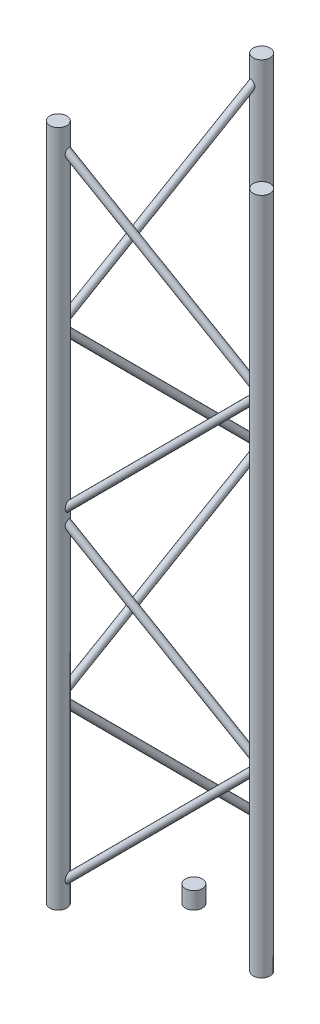
from build123d import *

# Parameters (mm, degrees)
SKETCH2_R                      = 25
BOSS_EXTRUDE2_DEPTH            = 50
SKETCH1_R                      = 25
BOSS_EXTRUDE1_DEPTH            = 2000
CIRPATTERN1_COUNT              = 3
SKETCH16_ON_SEGMENT_1_R        = 10.65
SKETCH16_ON_SEGMENT_1_R_2      = 8.35
PIPE_21_3_X_2_3_3_DEPTH        = 698.900964125
SKETCH16_ON_SEGMENT_2_R        = 10.65
SKETCH16_ON_SEGMENT_2_R_2      = 8.35
PIPE_21_3_X_2_3_3_2_DEPTH      = 715.434725051
SKETCH16_ON_SEGMENT_3_R        = 10.65
SKETCH16_ON_SEGMENT_3_R_2      = 8.35
PIPE_21_3_X_2_3_3_3_DEPTH      = 715.434725051
SKETCH16_R                     = 10.65
SKETCH16_R_2                   = 8.35
PIPE_21_3_X_2_3_3_4_DEPTH      = 682.367203198
PIPE_21_3_X_2_3_3_4_DEPTH_BACK = 16.533760927
CIRPATTERN2_COUNT              = 3


with BuildPart() as part:
    # Sketch2 → Boss-Extrude2 (new body)
    with BuildSketch(Plane(origin=(0, 0, 0), x_dir=(1, 0, 0), z_dir=(0, 1, 0))):
        with Locations(Location((0, 0, 0), (0, 0, 270))):  # turned: the seam where the file's is
            Circle(SKETCH2_R)
    extrude(amount=BOSS_EXTRUDE2_DEPTH)


with BuildPart() as body_2:
    # Sketch1 → Boss-Extrude1 (new body)
    with BuildSketch(Plane(origin=(0, 0, 0), x_dir=(1, 0, 0), z_dir=(0, 1, 0))):
        with Locations(Location((-200, -200, 0), (0, 0, 270))):  # turned: the seam where the file's is
            Circle(SKETCH1_R)
    extrude(amount=BOSS_EXTRUDE1_DEPTH)


with BuildPart() as cirpattern1_1:
    # CirPattern1: pattern copy
    add(body_2.part.rotate(Axis((0, 0, 0), (0, 1, 0)), 1 * 360 / CIRPATTERN1_COUNT))


with BuildPart() as cirpattern1_2:
    # CirPattern1: pattern copy
    add(body_2.part.rotate(Axis((0, 0, 0), (0, 1, 0)), 2 * 360 / CIRPATTERN1_COUNT))


with BuildPart() as body_5:
    # Sketch16 on segment 1 (carried to segment 1) → Pipe 21.3 X 2.3(3) (new body)
    with BuildSketch(Plane(origin=(273.205080757, 50, 73.205080757), x_dir=(-0.492221372, -0.717938884, -0.492221372), z_dir=(-0.507659454, 0.69610614, -0.507659454))):
        Circle(SKETCH16_ON_SEGMENT_1_R)
        Circle(SKETCH16_ON_SEGMENT_1_R_2, mode=Mode.SUBTRACT)
    extrude(amount=PIPE_21_3_X_2_3_3_DEPTH)

    # Pipe 21.3 X 2.3(3) mitre 1
    split(bisect_by=Plane(origin=(-73.205080757, 525, -273.205080757), x_dir=(1, 0, 0), z_dir=(0, -1, 0)), keep=Keep.TOP)


with BuildPart() as body_6:
    # Sketch16 on segment 2 (carried to segment 2) → Pipe 21.3 X 2.3_3 2 (new body)
    with BuildSketch(Plane(origin=(-81.598600795, 513.490747499, -281.598600795), x_dir=(-0.492221372, 0.717938884, -0.492221372), z_dir=(0.507659454, 0.69610614, 0.507659454))):
        Circle(SKETCH16_ON_SEGMENT_2_R)
        Circle(SKETCH16_ON_SEGMENT_2_R_2, mode=Mode.SUBTRACT)
    extrude(amount=PIPE_21_3_X_2_3_3_2_DEPTH)

    # Pipe 21.3 X 2.3_3 2 mitre 1
    split(bisect_by=Plane(origin=(-73.205080757, 525, -273.205080757), x_dir=(-1, 0, 0), z_dir=(0, 1, 0)), keep=Keep.TOP)

    # Pipe 21.3 X 2.3_3 2 mitre 2
    split(bisect_by=Plane(origin=(273.205080757, 1000, 73.205080757), x_dir=(1, 0, 0), z_dir=(0, -1, 0)), keep=Keep.TOP)


with BuildPart() as body_7:
    # Sketch16 on segment 3 (carried to segment 3) → Pipe 21.3 X 2.3_3 3 (new body)
    with BuildSketch(Plane(origin=(281.598600795, 988.490747499, 81.598600795), x_dir=(-0.492221372, -0.717938884, -0.492221372), z_dir=(-0.507659454, 0.69610614, -0.507659454))):
        Circle(SKETCH16_ON_SEGMENT_3_R)
        Circle(SKETCH16_ON_SEGMENT_3_R_2, mode=Mode.SUBTRACT)
    extrude(amount=PIPE_21_3_X_2_3_3_3_DEPTH)

    # Pipe 21.3 X 2.3_3 3 mitre 1
    split(bisect_by=Plane(origin=(273.205080757, 1000, 73.205080757), x_dir=(-1, 0, 0), z_dir=(0, 1, 0)), keep=Keep.TOP)

    # Pipe 21.3 X 2.3_3 3 mitre 2
    split(bisect_by=Plane(origin=(-73.205080757, 1475, -273.205080757), x_dir=(1, 0, 0), z_dir=(0, -1, 0)), keep=Keep.TOP)


with BuildPart() as body_8:
    # Sketch16 → Pipe 21.3 X 2.3_3 4 (new body, two sides)
    with BuildSketch(Plane(origin=(-73.205080757, 1475, -273.205080757), x_dir=(-0.492221372, 0.717938884, -0.492221372), z_dir=(0.507659454, 0.69610614, 0.507659454))) as pipe_21_3_x_2_3_3_4_sk:
        Circle(SKETCH16_R)
        Circle(SKETCH16_R_2, mode=Mode.SUBTRACT)
    extrude(amount=PIPE_21_3_X_2_3_3_4_DEPTH)
    extrude(pipe_21_3_x_2_3_3_4_sk.sketch, amount=-PIPE_21_3_X_2_3_3_4_DEPTH_BACK)

    # Pipe 21.3 X 2.3_3 4 mitre 1
    split(bisect_by=Plane(origin=(-73.205080757, 1475, -273.205080757), x_dir=(-1, 0, 0), z_dir=(0, 1, 0)), keep=Keep.TOP)


with BuildPart() as cirpattern2_1:
    # CirPattern2: pattern copy
    add(body_8.part.rotate(Axis((0, 0, 0), (0, 1, 0)), 1 * 360 / CIRPATTERN2_COUNT))


with BuildPart() as cirpattern2_2:
    # CirPattern2: pattern copy
    add(body_8.part.rotate(Axis((0, 0, 0), (0, 1, 0)), 2 * 360 / CIRPATTERN2_COUNT))


with BuildPart() as cirpattern2_3:
    # CirPattern2: pattern copy
    add(body_7.part.rotate(Axis((0, 0, 0), (0, 1, 0)), 1 * 360 / CIRPATTERN2_COUNT))


with BuildPart() as cirpattern2_4:
    # CirPattern2: pattern copy
    add(body_7.part.rotate(Axis((0, 0, 0), (0, 1, 0)), 2 * 360 / CIRPATTERN2_COUNT))


with BuildPart() as cirpattern2_5:
    # CirPattern2: pattern copy
    add(body_6.part.rotate(Axis((0, 0, 0), (0, 1, 0)), 1 * 360 / CIRPATTERN2_COUNT))


with BuildPart() as cirpattern2_6:
    # CirPattern2: pattern copy
    add(body_6.part.rotate(Axis((0, 0, 0), (0, 1, 0)), 2 * 360 / CIRPATTERN2_COUNT))


with BuildPart() as cirpattern2_7:
    # CirPattern2: pattern copy
    add(body_5.part.rotate(Axis((0, 0, 0), (0, 1, 0)), 1 * 360 / CIRPATTERN2_COUNT))


with BuildPart() as cirpattern2_8:
    # CirPattern2: pattern copy
    add(body_5.part.rotate(Axis((0, 0, 0), (0, 1, 0)), 2 * 360 / CIRPATTERN2_COUNT))


solid = Compound([part.part, body_2.part, cirpattern1_1.part, cirpattern1_2.part, body_5.part, body_6.part, body_7.part, body_8.part, cirpattern2_1.part, cirpattern2_2.part, cirpattern2_3.part, cirpattern2_4.part, cirpattern2_5.part, cirpattern2_6.part, cirpattern2_7.part, cirpattern2_8.part])
